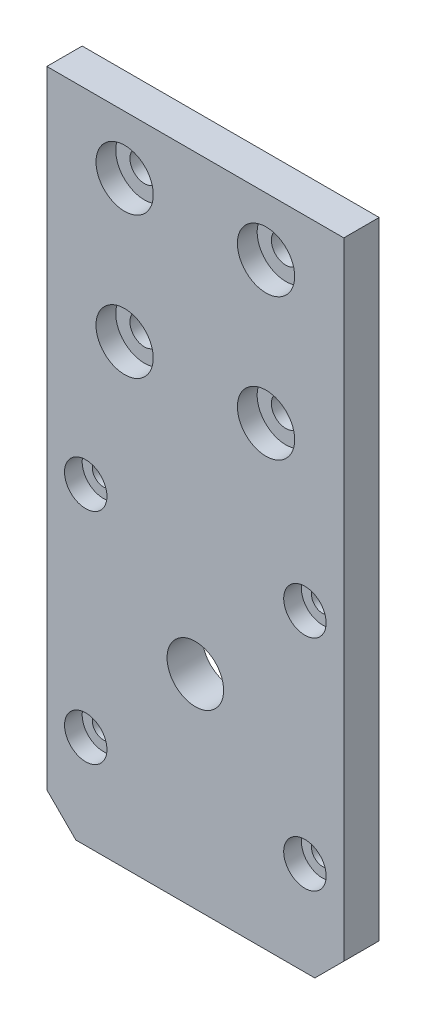
from build123d import *

# Parameters (mm, degrees)
CROQUIS1_W              = 42
CROQUIS1_H              = 85
CROQUIS1_R              = 2.05
SALIENTE_EXTRUIR1_DEPTH = 5
CROQUIS4_R              = 4.05
CORTAR_EXTRUIR1_DEPTH   = 2.8
CROQUIS5_R              = 1.575
CROQUIS5_R_2            = 4
CORTAR_EXTRUIR2_DEPTH   = 6
CROQUIS6_R              = 3
CORTAR_EXTRUIR3_DEPTH   = 2.5
CROQUIS7_W              = 42
CROQUIS7_H              = 7.7
SALIENTE_EXTRUIR2_DEPTH = 5
CHAFL_N1_SIZE           = 4.1


with BuildPart() as part:
    # Croquis1 → Saliente-Extruir1 (new body)
    with BuildSketch(Plane.XY):
        with Locations((21, 42.5)):
            Rectangle(CROQUIS1_W, CROQUIS1_H)
        with Locations((11, 76.8)):
            Circle(CROQUIS1_R, mode=Mode.SUBTRACT)
        with Locations((31, 76.8)):
            Circle(CROQUIS1_R, mode=Mode.SUBTRACT)
        with Locations((31, 56.8)):
            Circle(CROQUIS1_R, mode=Mode.SUBTRACT)
        with Locations((11, 56.8)):
            Circle(CROQUIS1_R, mode=Mode.SUBTRACT)
    extrude(amount=SALIENTE_EXTRUIR1_DEPTH)

    # Croquis4 → Cortar-Extruir1 (cut)
    with BuildSketch(Plane.XY.offset(5)):
        with Locations((11, 76.8)):
            Circle(CROQUIS4_R)
        with Locations((11, 56.8)):
            Circle(CROQUIS4_R)
        with Locations((31, 56.8)):
            Circle(CROQUIS4_R)
        with Locations((31, 76.8)):
            Circle(CROQUIS4_R)
    extrude(amount=-CORTAR_EXTRUIR1_DEPTH, mode=Mode.SUBTRACT)

    # Croquis5 → Cortar-Extruir2 (cut, through all)
    with BuildSketch(Plane.XY.offset(5)):
        with Locations((5.5, 36.58)):
            Circle(CROQUIS5_R)
        with Locations((36.5, 36.58)):
            Circle(CROQUIS5_R)
        with Locations((36.5, 5.58)):
            Circle(CROQUIS5_R)
        with Locations((5.5, 5.58)):
            Circle(CROQUIS5_R)
        with Locations((21, 21.08)):
            Circle(CROQUIS5_R_2)
    extrude(amount=-CORTAR_EXTRUIR2_DEPTH, mode=Mode.SUBTRACT)

    # Croquis6 → Cortar-Extruir3 (cut)
    with BuildSketch(Plane.XY.offset(5)):
        with Locations((5.5, 36.58)):
            Circle(CROQUIS6_R)
        with Locations((36.5, 36.58)):
            Circle(CROQUIS6_R)
        with Locations((36.5, 5.58)):
            Circle(CROQUIS6_R)
        with Locations((5.5, 5.58)):
            Circle(CROQUIS6_R)
    extrude(amount=-CORTAR_EXTRUIR3_DEPTH, mode=Mode.SUBTRACT)

    # Croquis7 → Saliente-Extruir2 (add, through all)
    with BuildSketch(Plane(origin=(0, 0, 0), x_dir=(-1, 0, 0), z_dir=(0, 0, -1))):
        with Locations((-21, -3.85)):
            Rectangle(CROQUIS7_W, CROQUIS7_H)
    extrude(amount=-SALIENTE_EXTRUIR2_DEPTH)

    # Chaflán1
    chafl_n1_edges = [part.edges().sort_by_distance(p)[0] for p in [
        (42, -7.7, 2.5),
        (0, -7.7, 2.5),
    ]]
    chamfer(chafl_n1_edges, length=CHAFL_N1_SIZE)


solid = part.part
